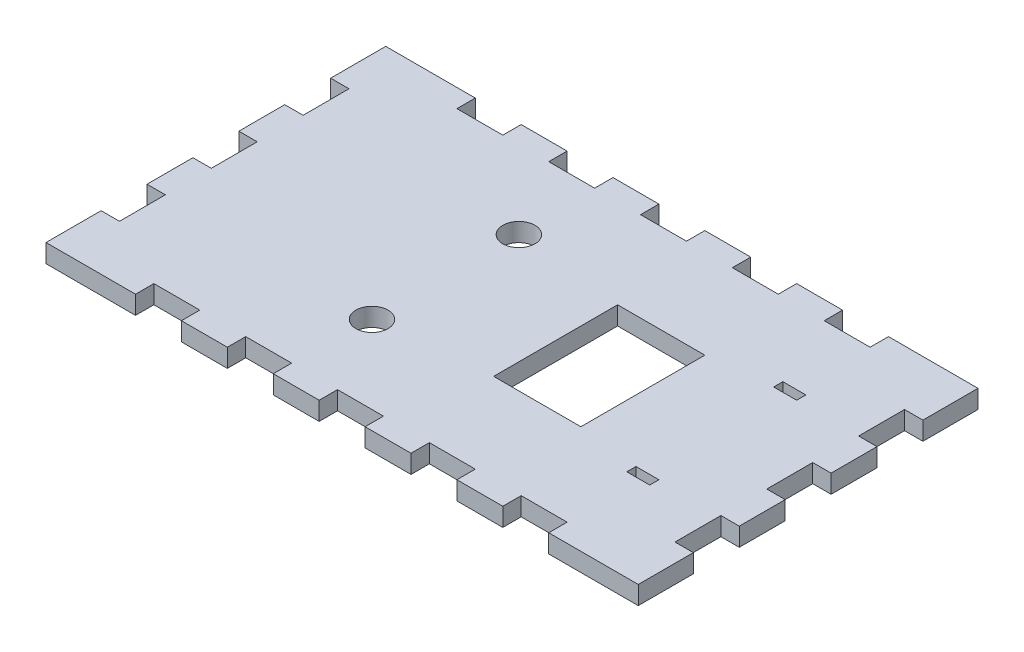
from build123d import *

# Parameters (mm, degrees)
SKETCH1_W           = 129
SKETCH1_H           = 74
BOSS_EXTRUDE1_DEPTH = 4
SKETCH2_R           = 3.5
SKETCH2_W           = 19
SKETCH2_H           = 27
CUT_EXTRUDE1_DEPTH  = 5
SKETCH3_W           = 5
SKETCH3_H           = 2
CUT_EXTRUDE2_DEPTH  = 5
SKETCH4_W           = 4
SKETCH4_H           = 10
SKETCH4_W_2         = 10
SKETCH4_H_2         = 4
CUT_EXTRUDE3_DEPTH  = 5


with BuildPart() as part:
    # Sketch1 → Boss-Extrude1 (new body)
    with BuildSketch(Plane(origin=(0, 0, 0), x_dir=(1, 0, 0), z_dir=(0, 1, 0))):
        with Locations((64.5, -37)):
            Rectangle(SKETCH1_W, SKETCH1_H)
    extrude(amount=BOSS_EXTRUDE1_DEPTH)

    # Sketch2 → Cut-Extrude1 (cut, through all)
    with BuildSketch(Plane(origin=(0, 4, 0), x_dir=(1, 0, 0), z_dir=(0, 1, 0))):
        with Locations((50, -21)):
            Circle(SKETCH2_R)
        with Locations((50, -53)):
            Circle(SKETCH2_R)
        with Locations((83.5, -37)):
            Rectangle(SKETCH2_W, SKETCH2_H)
    extrude(amount=-CUT_EXTRUDE1_DEPTH, mode=Mode.SUBTRACT)

    # Sketch3 → Cut-Extrude2 (cut, through all)
    with BuildSketch(Plane(origin=(0, 4, 0), x_dir=(1, 0, 0), z_dir=(0, 1, 0))):
        with Locations((109, -21)):
            Rectangle(SKETCH3_W, SKETCH3_H)
        with Locations((109, -53)):
            Rectangle(SKETCH3_W, SKETCH3_H)
    extrude(amount=-CUT_EXTRUDE2_DEPTH, mode=Mode.SUBTRACT)

    # Sketch4 → Cut-Extrude3 (cut, through all)
    with BuildSketch(Plane(origin=(0, 4, 0), x_dir=(1, 0, 0), z_dir=(0, 1, 0))):
        with Locations((127, -57)):
            Rectangle(SKETCH4_W, SKETCH4_H)
        with Locations((127, -37)):
            Rectangle(SKETCH4_W, SKETCH4_H)
        with Locations((127, -17)):
            Rectangle(SKETCH4_W, SKETCH4_H)
        with Locations((2, -57)):
            Rectangle(SKETCH4_W, SKETCH4_H)
        with Locations((2, -37)):
            Rectangle(SKETCH4_W, SKETCH4_H)
        with Locations((2, -17)):
            Rectangle(SKETCH4_W, SKETCH4_H)
        with Locations((104.5, -2)):
            Rectangle(SKETCH4_W_2, SKETCH4_H_2)
        with Locations((84.5, -2)):
            Rectangle(SKETCH4_W_2, SKETCH4_H_2)
        with Locations((64.5, -2)):
            Rectangle(SKETCH4_W_2, SKETCH4_H_2)
        with Locations((44.5, -2)):
            Rectangle(SKETCH4_W_2, SKETCH4_H_2)
        with Locations((24.5, -2)):
            Rectangle(SKETCH4_W_2, SKETCH4_H_2)
        with Locations((104.5, -72)):
            Rectangle(SKETCH4_W_2, SKETCH4_H_2)
        with Locations((84.5, -72)):
            Rectangle(SKETCH4_W_2, SKETCH4_H_2)
        with Locations((64.5, -72)):
            Rectangle(SKETCH4_W_2, SKETCH4_H_2)
        with Locations((44.5, -72)):
            Rectangle(SKETCH4_W_2, SKETCH4_H_2)
        with Locations((24.5, -72)):
            Rectangle(SKETCH4_W_2, SKETCH4_H_2)
    extrude(amount=-CUT_EXTRUDE3_DEPTH, mode=Mode.SUBTRACT)


solid = part.part
